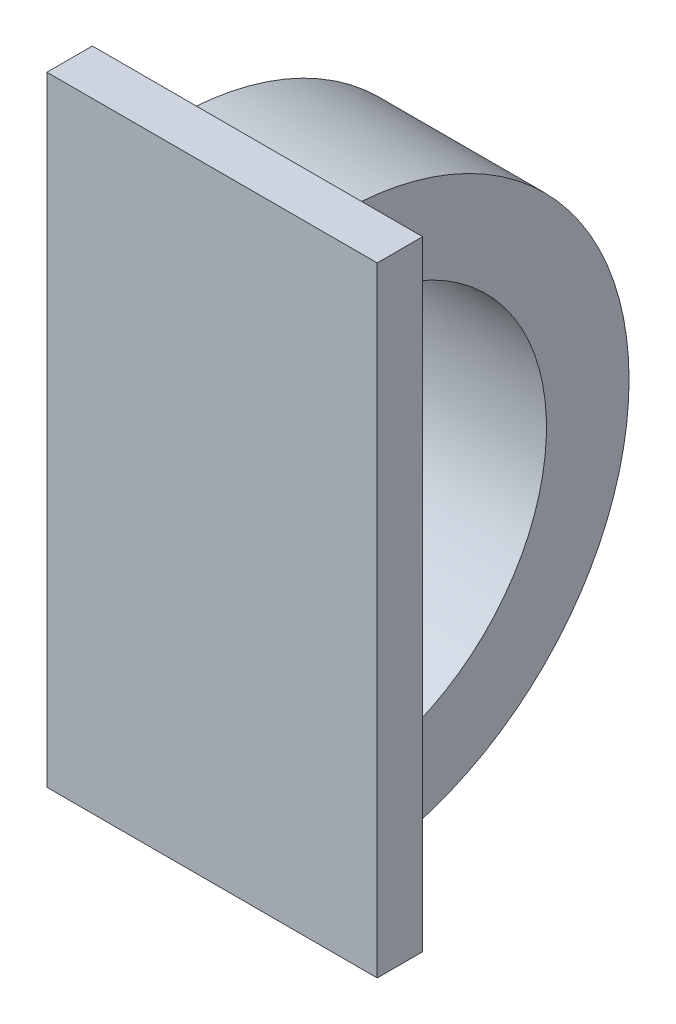
from build123d import *

# Parameters (mm, degrees)
CROQUIS1_W              = 8
CROQUIS1_H              = 15
SALIENTE_EXTRUIR6_DEPTH = 1.1
SALIENTE_EXTRUIR7_DEPTH = 2


with BuildPart() as part:
    # Croquis1 → Saliente-Extruir6 (new body)
    with BuildSketch(Plane.XY):
        Rectangle(CROQUIS1_W, CROQUIS1_H)
    extrude(amount=SALIENTE_EXTRUIR6_DEPTH)

    # Croquis8 → Saliente-Extruir7 (add, symmetric)
    with BuildSketch(Plane(origin=(0, 0, 0), x_dir=(0, 0, -1), z_dir=(1, 0, 0))):
        with BuildLine():
            Line((0, 7), (0, 5))
            ThreePointArc((0, 5), (5, 0), (0, -5))
            Line((0, -5), (0, -7))
            ThreePointArc((0, -7), (7, 0), (0, 7))
        make_face()
    extrude(amount=SALIENTE_EXTRUIR7_DEPTH, both=True)


solid = part.part
